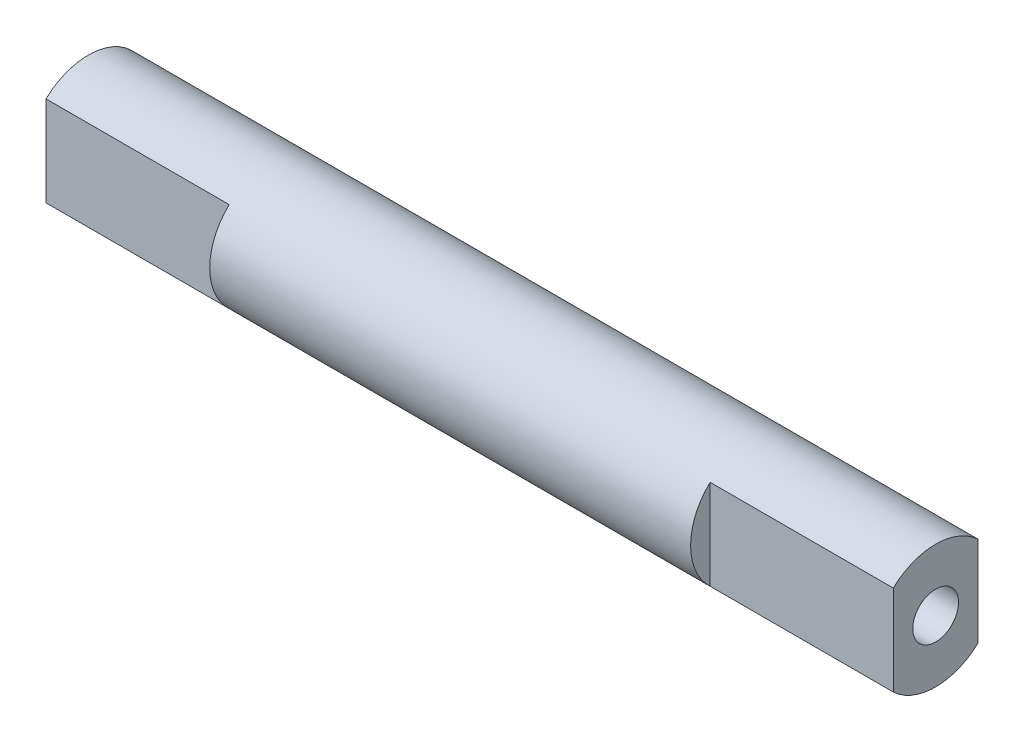
from build123d import *

# Parameters (mm, degrees)
SKETCH1_R           = 2.7
BOSS_EXTRUDE1_DEPTH = 18.5
CUT_EXTRUDE1_DEPTH  = 8
SKETCH3_R           = 1
CUT_EXTRUDE2_DEPTH  = 6


with BuildPart() as part:
    # Sketch1 → Boss-Extrude1 (new body, symmetric)
    with BuildSketch(Plane(origin=(0, 0, 0), x_dir=(0, 0, -1), z_dir=(1, 0, 0))):
        Circle(SKETCH1_R)
    extrude(amount=BOSS_EXTRUDE1_DEPTH, both=True)

    # Sketch2 → Cut-Extrude1 (cut)
    with BuildSketch(Plane(origin=(18.5, 0, 0), x_dir=(0, 0, -1), z_dir=(1, 0, 0))):
        with BuildLine():
            Line((-1.85, 1.966596044), (-1.85, -1.966596044))
            ThreePointArc((-1.85, -1.966596044), (-2.7, 0), (-1.85, 1.966596044))
        make_face()
        with BuildLine():
            Line((1.85, 1.966596044), (1.85, -1.966596044))
            ThreePointArc((1.85, -1.966596044), (2.7, 0), (1.85, 1.966596044))
        make_face()
    cut_extrude1 = extrude(amount=-CUT_EXTRUDE1_DEPTH, mode=Mode.SUBTRACT)

    # Sketch3 → Cut-Extrude2 (cut)
    with BuildSketch(Plane(origin=(18.5, 0, 0), x_dir=(0, 0, -1), z_dir=(1, 0, 0))):
        Circle(SKETCH3_R)
    cut_extrude2 = extrude(amount=-CUT_EXTRUDE2_DEPTH, mode=Mode.SUBTRACT)

    # Mirror1: Cut-Extrude1, Cut-Extrude2 across plane
    add(cut_extrude1.mirror(Plane(origin=(0, 0, 0), x_dir=(0, 0, 1), z_dir=(1, 0, 0))), mode=Mode.SUBTRACT)
    add(cut_extrude2.mirror(Plane(origin=(0, 0, 0), x_dir=(0, 0, 1), z_dir=(1, 0, 0))), mode=Mode.SUBTRACT)


solid = part.part
